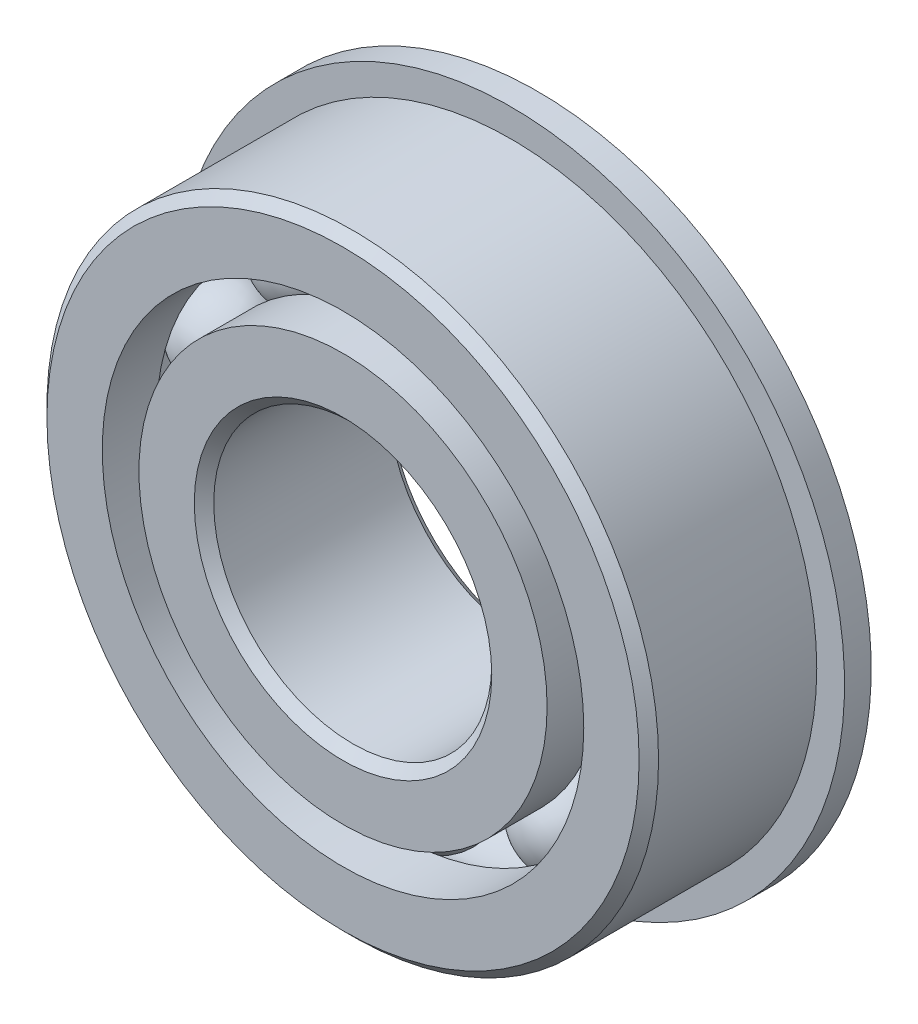
from build123d import *

# Parameters (mm, degrees)
CIRPATTERN1_COUNT = 10
SKETCH6_W         = 1.524
SKETCH6_H         = 5.303296703


with BuildPart() as part:
    # Sketch1 → Revolve1 (revolve)
    with BuildSketch(Plane(origin=(0, 0, 0), x_dir=(0, 0, -1), z_dir=(1, 0, 0))):
        with BuildLine():
            Line((5.000625, 17.4625), (-5.000625, 17.4625))
            Line((-5.000625, 17.4625), (-5.55625, 16.906875))
            Line((-5.55625, 16.906875), (-5.55625, 13.746703297))
            Line((-5.55625, 13.746703297), (-2.469444444, 13.746703297))
            ThreePointArc((-2.469444444, 13.746703297), (0, 15.382115519), (2.469444444, 13.746703297))
            Line((2.469444444, 13.746703297), (5.55625, 13.746703297))
            Line((5.55625, 13.746703297), (5.55625, 16.906875))
            Line((5.55625, 16.906875), (5.000625, 17.4625))
        make_face()
    revolve(axis=Axis((0, 0, 5.55625), (0, 0, -1)))

    # Sketch6 → Revolve6 (revolve)
    with BuildSketch(Plane(origin=(0, 0, 0), x_dir=(0, 0, -1), z_dir=(1, 0, 0))):
        with Locations((4.79425, 16.398351649)):
            Rectangle(SKETCH6_W, SKETCH6_H)
    revolve(axis=Axis((0, 0, -5.55625), (0, 0, 1)))


with BuildPart() as body_2:
    # Sketch3 → Revolve3 (revolve)
    with BuildSketch(Plane(origin=(0, 0, 0), x_dir=(0, 0, -1), z_dir=(1, 0, 0))):
        with BuildLine():
            Line((-5.55625, 11.653296703), (-2.469444444, 11.653296703))
            ThreePointArc((-2.469444444, 11.653296703), (0, 10.017884481), (2.469444444, 11.653296703))
            Line((2.469444444, 11.653296703), (5.55625, 11.653296703))
            Line((5.55625, 11.653296703), (5.55625, 8.493125))
            Line((5.55625, 8.493125), (5.000625, 7.9375))
            Line((5.000625, 7.9375), (-5.000625, 7.9375))
            Line((-5.000625, 7.9375), (-5.55625, 8.493125))
            Line((-5.55625, 8.493125), (-5.55625, 11.653296703))
        make_face()
    revolve(axis=Axis((0, 0, 5.55625), (0, 0, -1)))


with BuildPart() as body_3:
    # Sketch4 → Revolve4 (revolve)
    with BuildSketch(Plane(origin=(0, 0, 0), x_dir=(0, 0, -1), z_dir=(1, 0, 0))):
        with BuildLine():
            Line((-2.682115519, 12.7), (2.682115519, 12.7))
            ThreePointArc((2.682115519, 12.7), (0, 15.382115519), (-2.682115519, 12.7))
        make_face()
    revolve(axis=Axis((0, 12.7, 2.682115519), (0, 0, -1)))


with BuildPart() as cirpattern1_1:
    # CirPattern1: pattern copy
    add(body_3.part.rotate(Axis((0, 0, -5.55625), (0, 0, 1)), 1 * 360 / CIRPATTERN1_COUNT))


with BuildPart() as cirpattern1_2:
    # CirPattern1: pattern copy
    add(body_3.part.rotate(Axis((0, 0, -5.55625), (0, 0, 1)), 2 * 360 / CIRPATTERN1_COUNT))


with BuildPart() as cirpattern1_3:
    # CirPattern1: pattern copy
    add(body_3.part.rotate(Axis((0, 0, -5.55625), (0, 0, 1)), 3 * 360 / CIRPATTERN1_COUNT))


with BuildPart() as cirpattern1_4:
    # CirPattern1: pattern copy
    add(body_3.part.rotate(Axis((0, 0, -5.55625), (0, 0, 1)), 4 * 360 / CIRPATTERN1_COUNT))


with BuildPart() as cirpattern1_5:
    # CirPattern1: pattern copy
    add(body_3.part.rotate(Axis((0, 0, -5.55625), (0, 0, 1)), 5 * 360 / CIRPATTERN1_COUNT))


with BuildPart() as cirpattern1_6:
    # CirPattern1: pattern copy
    add(body_3.part.rotate(Axis((0, 0, -5.55625), (0, 0, 1)), 6 * 360 / CIRPATTERN1_COUNT))


with BuildPart() as cirpattern1_7:
    # CirPattern1: pattern copy
    add(body_3.part.rotate(Axis((0, 0, -5.55625), (0, 0, 1)), 7 * 360 / CIRPATTERN1_COUNT))


with BuildPart() as cirpattern1_8:
    # CirPattern1: pattern copy
    add(body_3.part.rotate(Axis((0, 0, -5.55625), (0, 0, 1)), 8 * 360 / CIRPATTERN1_COUNT))


with BuildPart() as cirpattern1_9:
    # CirPattern1: pattern copy
    add(body_3.part.rotate(Axis((0, 0, -5.55625), (0, 0, 1)), 9 * 360 / CIRPATTERN1_COUNT))


solid = Compound([part.part, body_2.part, body_3.part, cirpattern1_1.part, cirpattern1_2.part, cirpattern1_3.part, cirpattern1_4.part, cirpattern1_5.part, cirpattern1_6.part, cirpattern1_7.part, cirpattern1_8.part, cirpattern1_9.part])
